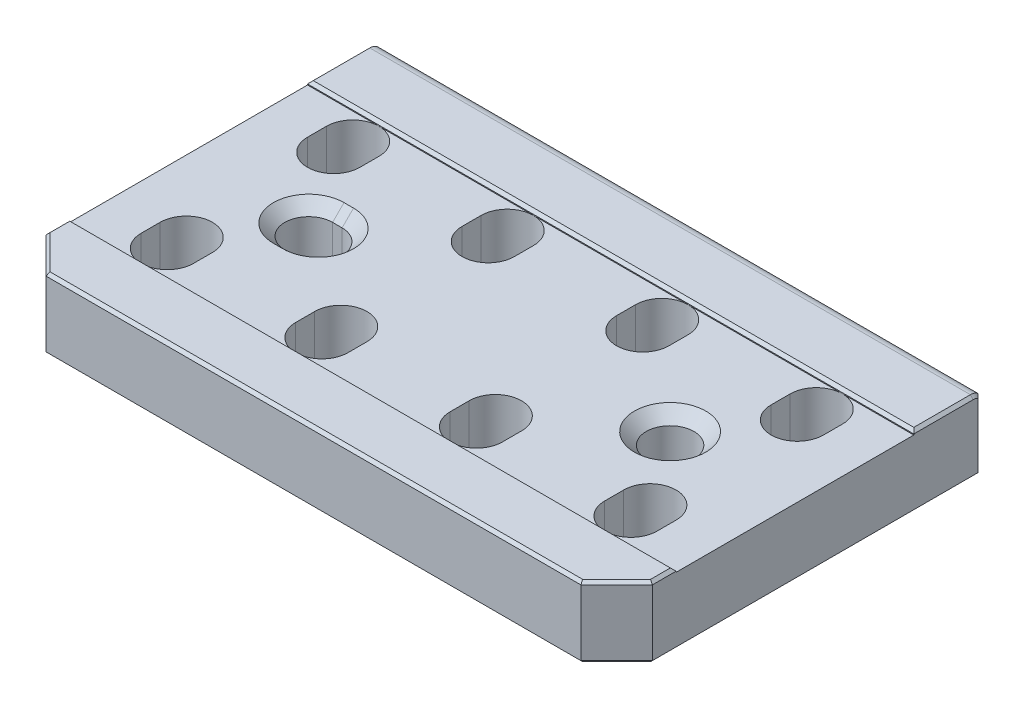
from build123d import *

# Parameters (mm, degrees)
SKETCH1_W      = 95.25
SKETCH1_H      = 19.05
EXTRUDE1_DEPTH = 80.9625
CHAMFER1_SIZE  = 9.525
SKETCH6_W      = 161.925
SKETCH6_H      = 63.5
EXTRUDE2_DEPTH = 1.016
EXTRUDE5_DEPTH = 80.9625
EXTRUDE8_DEPTH = 20.05
CHAMFER8_SIZE  = 0.762
EXTRUDE9_DEPTH = 19.034
CHAMFER9_SIZE  = 3.048
CHAMFER6_SIZE  = 0.762


with BuildPart() as part:
    # Sketch1 → Extrude1 (new body, symmetric)
    with BuildSketch(Plane(origin=(0, 0, 0), x_dir=(0, 0, -1), z_dir=(1, 0, 0))):
        with Locations((0, 9.525)):
            Rectangle(SKETCH1_W, SKETCH1_H)
    extrude(amount=EXTRUDE1_DEPTH, both=True)

    # Chamfer1
    chamfer1_edges = [part.edges().sort_by_distance(p)[0] for p in [
        (80.9625, 9.525, 47.625),
        (-80.9625, 9.525, 47.625),
    ]]
    chamfer(chamfer1_edges, length=CHAMFER1_SIZE)

    # Sketch6 → Extrude2 (cut)
    with BuildSketch(Plane(origin=(0, 19.05, 0), x_dir=(1, 0, 0), z_dir=(0, 1, 0))):
        Rectangle(SKETCH6_W, SKETCH6_H)
    extrude(amount=-EXTRUDE2_DEPTH, mode=Mode.SUBTRACT)

    # Sketch10 → Extrude5 (add, symmetric)
    with BuildSketch(Plane(origin=(0, 0, 0), x_dir=(0, 0, -1), z_dir=(1, 0, 0))):
        with BuildLine():
            Line((47.117, 19.05), (47.117, 0))
            Line((47.117, 0), (49.657, 0))
            Line((49.657, 0), (49.657, 18.314590334))
            ThreePointArc((49.657, 18.314590334), (48.705491945, 18.860491945), (47.625, 19.05))
            Line((47.625, 19.05), (47.117, 19.05))
        make_face()
    extrude(amount=EXTRUDE5_DEPTH, both=True)

    # Sketch16 → Extrude8 (cut, through all)
    with BuildSketch(Plane.XZ):
        with BuildLine():
            Line((-54.9275, 24.765), (-54.9275, 19.685))
            ThreePointArc((-54.9275, 19.685), (-61.9125, 12.7), (-68.8975, 19.685))
            Line((-68.8975, 19.685), (-68.8975, 24.765))
            ThreePointArc((-68.8975, 24.765), (-61.9125, 31.75), (-54.9275, 24.765))
        make_face()
        with BuildLine():
            Line((-54.9275, -19.685), (-54.9275, -24.765))
            ThreePointArc((-54.9275, -24.765), (-61.9125, -31.75), (-68.8975, -24.765))
            Line((-68.8975, -24.765), (-68.8975, -19.685))
            ThreePointArc((-68.8975, -19.685), (-61.9125, -12.7), (-54.9275, -19.685))
        make_face()
        with BuildLine():
            Line((-13.6525, -19.685), (-13.6525, -24.765))
            ThreePointArc((-13.6525, -24.765), (-20.6375, -31.75), (-27.6225, -24.765))
            Line((-27.6225, -24.765), (-27.6225, -19.685))
            ThreePointArc((-27.6225, -19.685), (-20.6375, -12.7), (-13.6525, -19.685))
        make_face()
        with BuildLine():
            Line((27.6225, -19.685), (27.6225, -24.765))
            ThreePointArc((27.6225, -24.765), (20.6375, -31.75), (13.6525, -24.765))
            Line((13.6525, -24.765), (13.6525, -19.685))
            ThreePointArc((13.6525, -19.685), (20.6375, -12.7), (27.6225, -19.685))
        make_face()
        with BuildLine():
            Line((68.8975, -19.685), (68.8975, -24.765))
            ThreePointArc((68.8975, -24.765), (61.9125, -31.75), (54.9275, -24.765))
            Line((54.9275, -24.765), (54.9275, -19.685))
            ThreePointArc((54.9275, -19.685), (61.9125, -12.7), (68.8975, -19.685))
        make_face()
        with BuildLine():
            Line((68.8975, 24.765), (68.8975, 19.685))
            ThreePointArc((68.8975, 19.685), (61.9125, 12.7), (54.9275, 19.685))
            Line((54.9275, 19.685), (54.9275, 24.765))
            ThreePointArc((54.9275, 24.765), (61.9125, 31.75), (68.8975, 24.765))
        make_face()
        with BuildLine():
            Line((27.6225, 24.765), (27.6225, 19.685))
            ThreePointArc((27.6225, 19.685), (20.6375, 12.7), (13.6525, 19.685))
            Line((13.6525, 19.685), (13.6525, 24.765))
            ThreePointArc((13.6525, 24.765), (20.6375, 31.75), (27.6225, 24.765))
        make_face()
        with BuildLine():
            Line((-13.6525, 24.765), (-13.6525, 19.685))
            ThreePointArc((-13.6525, 19.685), (-20.6375, 12.7), (-27.6225, 19.685))
            Line((-27.6225, 19.685), (-27.6225, 24.765))
            ThreePointArc((-27.6225, 24.765), (-20.6375, 31.75), (-13.6525, 24.765))
        make_face()
    extrude(amount=-EXTRUDE8_DEPTH, mode=Mode.SUBTRACT)

    # Chamfer8
    chamfer8_edges = [part.edges().sort_by_distance(p)[0] for p in [
        (-20.6375, 0, -12.7),
        (-27.6225, 0, -22.225),
        (-20.6375, 0, -31.75),
        (-13.6525, 0, -22.225),
        (20.6375, 0, -12.7),
        (13.6525, 0, -22.225),
        (20.6375, 0, -31.75),
        (27.6225, 0, -22.225),
        (61.9125, 0, -12.7),
        (54.9275, 0, -22.225),
        (61.9125, 0, -31.75),
        (68.8975, 0, -22.225),
        (61.9125, 0, 31.75),
        (54.9275, 0, 22.225),
        (61.9125, 0, 12.7),
        (68.8975, 0, 22.225),
        (20.6375, 0, 31.75),
        (13.6525, 0, 22.225),
        (20.6375, 0, 12.7),
        (27.6225, 0, 22.225),
        (-20.6375, 0, 31.75),
        (-27.6225, 0, 22.225),
        (-20.6375, 0, 12.7),
        (-13.6525, 0, 22.225),
        (-61.9125, 0, 31.75),
        (-68.8975, 0, 22.225),
        (-61.9125, 0, 12.7),
        (-54.9275, 0, 22.225),
        (-61.9125, 0, -12.7),
        (-68.8975, 0, -22.225),
        (-61.9125, 0, -31.75),
        (-54.9275, 0, -22.225),
    ]]
    chamfer(chamfer8_edges, length=CHAMFER8_SIZE)

    # Sketch17 → 1/2 (0.5) Diameter Hole2 (revolve, cut)
    with BuildSketch(Plane(origin=(47.625, 18.034, 0), x_dir=(0, 0, 1), z_dir=(1, 0, 0))):
        Polygon((0, 0), (0, 18.034), (9.525, 18.034), (6.3754, 14.8844), (6.3754, 3.1496), (9.525, 0), align=None)
    revolve(axis=Axis((47.625, 24.384, 0), (0, -1, 0)), mode=Mode.SUBTRACT)

    # Sketch20 → Extrude9 (cut, through all)
    with BuildSketch(Plane(origin=(0, 18.034, 0), x_dir=(1, 0, 0), z_dir=(0, 1, 0))):
        with BuildLine():
            Line((-48.895, 6.3754), (-46.355, 6.3754))
            ThreePointArc((-46.355, 6.3754), (-39.9796, 0), (-46.355, -6.3754))
            Line((-46.355, -6.3754), (-48.895, -6.3754))
            ThreePointArc((-48.895, -6.3754), (-55.2704, 0), (-48.895, 6.3754))
        make_face()
    extrude(amount=-EXTRUDE9_DEPTH, mode=Mode.SUBTRACT)

    # Chamfer9
    chamfer9_edges = [part.edges().sort_by_distance(p)[0] for p in [
        (-55.2704, 0, 0),
        (-47.625, 0, -6.3754),
        (-39.9796, 0, 0),
        (-47.625, 0, 6.3754),
        (-55.2704, 18.034, 0),
        (-47.625, 18.034, 6.3754),
        (-39.9796, 18.034, 0),
        (-47.625, 18.034, -6.3754),
    ]]
    chamfer(chamfer9_edges, length=CHAMFER9_SIZE)

    # Chamfer6
    chamfer6_edges = [part.edges().sort_by_distance(p)[0] for p in [
        (80.9625, 19.05, -39.6875),
        (0, 0, 47.625),
        (0, 19.05, 47.625),
        (-80.9625, 0, -5.7785),
        (80.9625, 0, -5.7785),
        (76.2, 0, 42.8625),
        (-76.2, 0, 42.8625),
        (76.2, 19.05, 42.8625),
        (-76.2, 19.05, 42.8625),
        (-80.9625, 19.05, 34.925),
        (80.9625, 19.05, 34.925),
        (0, 19.05, 31.75),
        (0, 19.05, -31.75),
        (-80.9625, 19.05, -39.6875),
        (80.9625, 9.157295167, -49.657),
        (80.9625, 18.860491945, -48.705491945),
        (0, 0, -49.657),
        (-80.9625, 18.860491945, -48.705491945),
        (-80.9625, 9.157295167, -49.657),
    ]]
    chamfer(chamfer6_edges, length=CHAMFER6_SIZE)


solid = part.part
